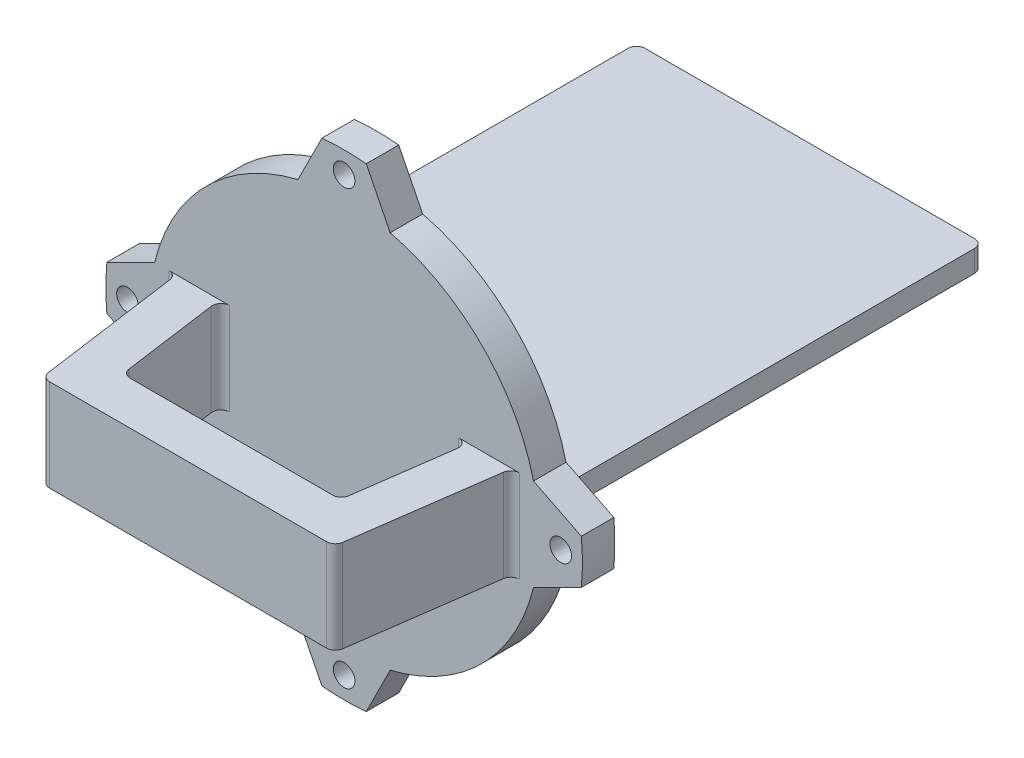
from build123d import *

# Parameters (mm, degrees)
SKETCH2_R           = 3.175
BOSS_EXTRUDE1_DEPTH = 9.525
SKETCH4_W           = 12.7
SKETCH4_H           = 27.0197796
SKETCH9_W           = 12.7
SKETCH9_H           = 27.0197796
SKETCH4_86_W        = 12.7
SKETCH4_86_H        = 27.0197796
SKETCH9_5_W         = 12.7
SKETCH9_5_H         = 27.0197796
SKETCH11_W          = 85.660440798
SKETCH11_H          = 27.0197796
BOSS_EXTRUDE3_DEPTH = 12.7
FILLET2_R           = 2.54
SKETCH12_W          = 101.6
SKETCH12_H          = 6.35
BOSS_EXTRUDE4_DEPTH = 127
FILLET4_R           = 2.54


with BuildPart() as part:
    # Sketch2 → Boss-Extrude1 (new body)
    with BuildSketch(Plane.XY):
        with BuildLine():
            Line((6.501621467, 69.546757065), (13.5098898, 55.530220399))
            ThreePointArc((13.5098898, 55.530220399), (40.411152545, 40.411152545), (55.530220399, 13.5098898))
            Line((55.530220399, 13.5098898), (69.546757065, 6.501621467))
            ThreePointArc((69.546757065, 6.501621467), (69.85, 0), (69.546757065, -6.501621467))
            Line((69.546757065, -6.501621467), (55.530220399, -13.5098898))
            ThreePointArc((55.530220399, -13.5098898), (40.411152545, -40.411152545), (13.5098898, -55.530220399))
            Line((13.5098898, -55.530220399), (6.501621467, -69.546757065))
            ThreePointArc((6.501621467, -69.546757065), (0, -69.85), (-6.501621467, -69.546757065))
            Line((-6.501621467, -69.546757065), (-13.5098898, -55.530220399))
            ThreePointArc((-13.5098898, -55.530220399), (-40.411152545, -40.411152545), (-55.530220399, -13.5098898))
            Line((-55.530220399, -13.5098898), (-69.546757065, -6.501621467))
            ThreePointArc((-69.546757065, -6.501621467), (-69.85, 0), (-69.546757065, 6.501621467))
            Line((-69.546757065, 6.501621467), (-55.530220399, 13.5098898))
            ThreePointArc((-55.530220399, 13.5098898), (-40.411152545, 40.411152545), (-13.5098898, 55.530220399))
            Line((-13.5098898, 55.530220399), (-6.501621467, 69.546757065))
            ThreePointArc((-6.501621467, 69.546757065), (0, 69.85), (6.501621467, 69.546757065))
        make_face()
        with Locations((-63.5, 0)):
            Circle(SKETCH2_R, mode=Mode.SUBTRACT)
        with Locations((0, 63.5)):
            Circle(SKETCH2_R, mode=Mode.SUBTRACT)
        with Locations((63.5, 0)):
            Circle(SKETCH2_R, mode=Mode.SUBTRACT)
        with Locations((0, -63.5)):
            Circle(SKETCH2_R, mode=Mode.SUBTRACT)
    extrude(amount=BOSS_EXTRUDE1_DEPTH)

    # Sketch4 → Loft5 section 0
    with BuildSketch(Plane.XY.offset(9.525)):
        with Locations((-42.830220399, 0)):
            Rectangle(SKETCH4_W, SKETCH4_H)
    # Sketch9 → Loft5 section 1
    with BuildSketch(Plane.XY.offset(55.245)):
        with Locations((-36.480220399, 0)):
            Rectangle(SKETCH9_W, SKETCH9_H)
    loft()

    # Sketch4_86 → Loft6 section 0
    with BuildSketch(Plane.XY.offset(9.525)):
        with Locations((42.830220399, 0)):
            Rectangle(SKETCH4_86_W, SKETCH4_86_H)
    # Sketch9_5 → Loft6 section 1
    with BuildSketch(Plane.XY.offset(55.245)):
        with Locations((36.480220399, 0)):
            Rectangle(SKETCH9_5_W, SKETCH9_5_H)
    loft()

    # Sketch11 → Boss-Extrude3 (add)
    with BuildSketch(Plane.XY.offset(55.245)):
        Rectangle(SKETCH11_W, SKETCH11_H)
    extrude(amount=-BOSS_EXTRUDE3_DEPTH)

    # Fillet2
    fillet2_edges = [part.edges().sort_by_distance(p)[0] for p in [
        (-31.894109288, 0, 42.545),
        (31.894109288, 0, 42.545),
        (-42.830220399, 0, 55.245),
        (-49.180220399, 0, 9.525),
        (-36.480220399, 0, 9.525),
        (36.480220399, 0, 9.525),
        (42.830220399, 0, 55.245),
        (49.180220399, 0, 9.525),
    ]]
    fillet(fillet2_edges, radius=FILLET2_R)

    # Sketch12 → Boss-Extrude4 (add)
    with BuildSketch(Plane(origin=(0, 0, 0), x_dir=(-1, 0, 0), z_dir=(0, 0, -1))):
        Rectangle(SKETCH12_W, SKETCH12_H)
    extrude(amount=BOSS_EXTRUDE4_DEPTH)

    # Fillet4
    fillet4_edges = [part.edges().sort_by_distance(p)[0] for p in [
        (-50.8, 0, 0),
        (50.8, 0, 0),
        (-50.8, 0, -127),
        (50.8, 0, -127),
    ]]
    fillet(fillet4_edges, radius=FILLET4_R)


solid = part.part
